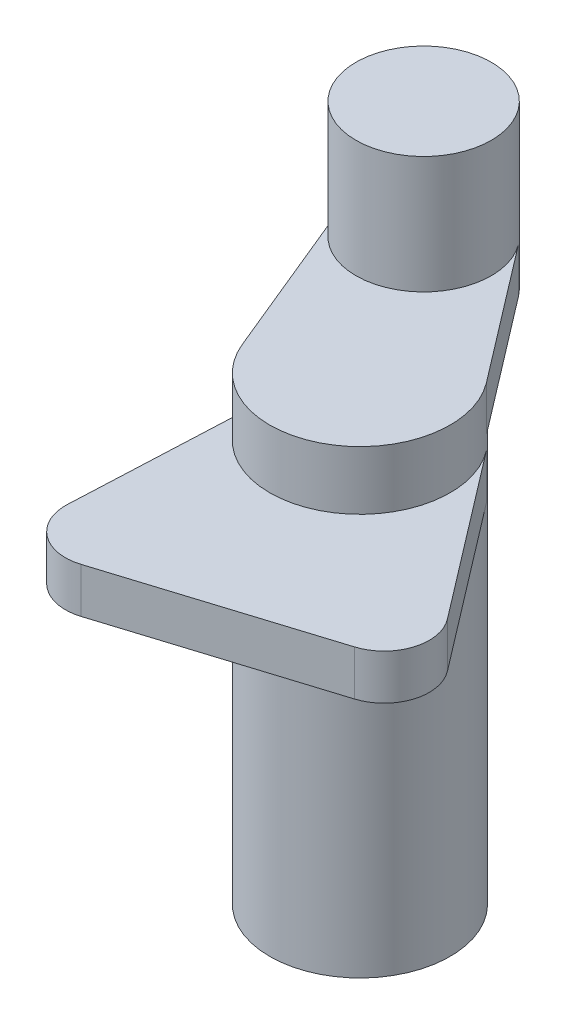
from build123d import *

# Parameters (mm, degrees)
SKETCH1_R           = 20
BOSS_EXTRUDE1_DEPTH = 51
BOSS_EXTRUDE2_DEPTH = 10
BOSS_EXTRUDE3_START = 26
BOSS_EXTRUDE3_DEPTH = 26
BOSS_EXTRUDE4_START = -10
BOSS_EXTRUDE4_DEPTH = 10


with BuildPart() as part:
    # Sketch1 → Boss-Extrude1 (new, symmetric)
    with BuildSketch(Plane(origin=(0, 0, 0), x_dir=(1, 0, 0), z_dir=(0, 1, 0))):
        Circle(SKETCH1_R)
    extrude(amount=BOSS_EXTRUDE1_DEPTH, both=True)

    # Sketch2 → Boss-Extrude2 (add)
    with BuildSketch(Plane(origin=(0, 51, 0), x_dir=(1, 0, 0), z_dir=(0, 1, 0))):
        with BuildLine():
            Line((15.889530325, 12.145897498), (-7.174782394, 42.319138828))
            ThreePointArc((-7.174782394, 42.319138828), (-26.567920967, 46.213928911), (-32.960703114, 27.495073445))
            Line((-32.960703114, 27.495073445), (-18.491697301, -7.619523011))
            ThreePointArc((-18.491697301, -7.619523011), (9.967987772, -17.338950942), (15.889530325, 12.145897498))
        make_face()
    extrude(amount=-BOSS_EXTRUDE2_DEPTH)

    # Sketch2_3 → Boss-Extrude3 (add)
    with BuildSketch(Plane(origin=(0, 51, 0), x_dir=(1, 0, 0), z_dir=(0, 1, 0)).offset(BOSS_EXTRUDE3_START)):
        with BuildLine():
            ThreePointArc((-4.091930138, 33.209715704), (-4.883530929, 38.018186554), (-7.174782394, 42.319138828))
            ThreePointArc((-7.174782394, 42.319138828), (-26.567920967, 46.213928911), (-32.960703114, 27.495073445))
            ThreePointArc((-32.960703114, 27.495073445), (-16.179164668, 18.495239929), (-4.091930138, 33.209715704))
        make_face()
    extrude(amount=-BOSS_EXTRUDE3_DEPTH)

    # Sketch3 → Boss-Extrude4 (add)
    with BuildSketch(Plane(origin=(0, 28, 0), x_dir=(-1, 0, 0), z_dir=(0, -1, 0)).offset(BOSS_EXTRUDE4_START)):
        with BuildLine():
            Line((18.491697301, -7.619523011), (20.177187538, -44.653612428))
            ThreePointArc((20.177187538, -44.653612428), (16.289787181, -53.030534966), (7.198092717, -54.650968393))
            Line((7.198092717, -54.650968393), (-38.995361437, -40.179987261))
            ThreePointArc((-38.995361437, -40.179987261), (-45.537524503, -33.661949585), (-43.950691193, -24.564330513))
            Line((-43.950691193, -24.564330513), (-15.889530325, 12.145897498))
            ThreePointArc((-15.889530325, 12.145897498), (-9.967987772, -17.338950942), (18.491697301, -7.619523011))
        make_face()
    extrude(amount=BOSS_EXTRUDE4_DEPTH)


solid = part.part
